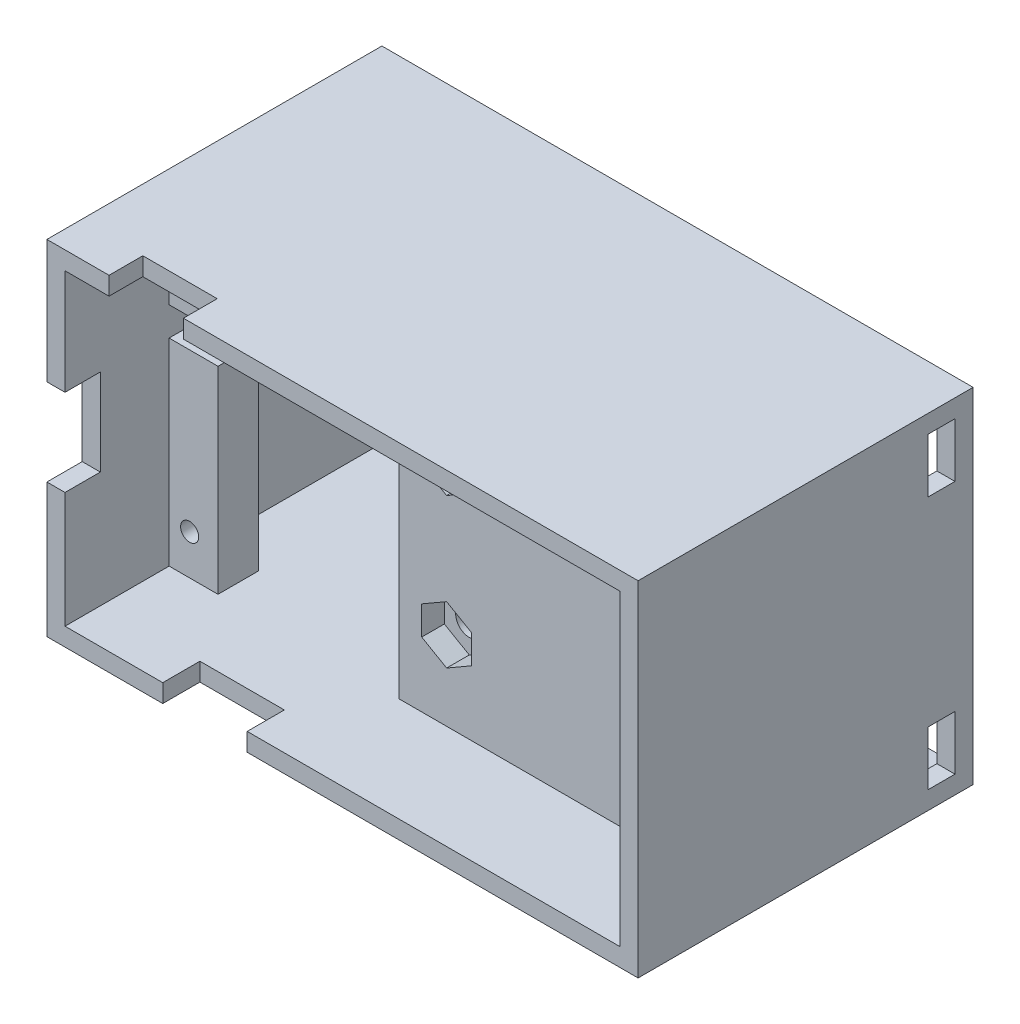
from build123d import *

# Parameters (mm, degrees)
SKETCH_2_W           = 65.2997206
SKETCH_2_H           = 38
SKETCH_2_R           = 1.00000254
SKETCH_2_R_2         = 0.922218434
SKETCH_2_R_3         = 1.5
EXTRUDE_2_DEPTH      = 4.5
SKETCH_3_R           = 1.5
CUT_EXTRUDE_2_DEPTH  = 2.5
SKETCH_5_W           = 65.2997206
SKETCH_5_H           = 38
SKETCH_5_W_2         = 61.2997206
SKETCH_5_H_2         = 34
EXTRUDE_3_DEPTH      = 21
EXTRUDE_3_DEPTH_BACK = 16
SKETCH_7_W           = 8.214112973
SKETCH_7_H           = 3.795011114
CUT_EXTRUDE_4_DEPTH  = 3
SKETCH_8_W           = 4
SKETCH_8_H           = 9.575559499
CUT_EXTRUDE_5_DEPTH  = 3
SKETCH_9_W           = 9.326303795
SKETCH_9_H           = 4.202278939
CUT_EXTRUDE_6_DEPTH  = 3
CUT_EXTRUDE_7_DEPTH  = 10
SKETCH_15_R          = 1.75
CUT_EXTRUDE_8_DEPTH  = 1.5
SKETCH_18_W          = 62.2997206
SKETCH_18_H          = 36
CUT_EXTRUDE_9_DEPTH  = 3
SKETCH_19_W          = 3
SKETCH_19_H          = 6
CUT_EXTRUDE_10_DEPTH = 2
SKETCH_20_W          = 2
SKETCH_20_H          = 8
CUT_EXTRUDE_11_DEPTH = 3
SKETCH_21_W          = 4.5
SKETCH_21_H          = 8
EXTRUDE_4_DEPTH      = 8
SKETCH_22_R          = 1.5
CUT_EXTRUDE_12_DEPTH = 10
CUT_EXTRUDE_13_DEPTH = 2.5
FILLET_1_R           = 1


with BuildPart() as part:
    # 草图2 → 凸台-拉伸2 (new body)
    with BuildSketch(Plane(origin=(0, 0, -6), x_dir=(-1, 0, 0), z_dir=(0, 0, -1))):
        with Locations((29.273558547, -24.066548133)):
            Rectangle(SKETCH_2_W, SKETCH_2_H)
        with Locations((1.016002032, -11.24978156)):
            Circle(SKETCH_2_R, mode=Mode.SUBTRACT)
        with Locations((0.889001778, -36.83007366)):
            Circle(SKETCH_2_R, mode=Mode.SUBTRACT)
        with Locations((57.658115316, -36.64983236)):
            Circle(SKETCH_2_R, mode=Mode.SUBTRACT)
        with Locations((57.658115316, -11.24978156)):
            Circle(SKETCH_2_R_2, mode=Mode.SUBTRACT)
        with Locations((29.273558547, -32.316548133)):
            Circle(SKETCH_2_R_3, mode=Mode.SUBTRACT)
        with BuildLine():
            Line((27.785407033, -15.816548133), (27.785407033, -13.183619987))
            ThreePointArc((27.785407033, -13.183619987), (29.273558547, -11.695468472), (30.761710061, -13.183619987))
            Line((30.761710061, -13.183619987), (30.761710061, -15.816548133))
            ThreePointArc((30.761710061, -15.816548133), (29.273558547, -17.304699647), (27.785407033, -15.816548133))
        make_face(mode=Mode.SUBTRACT)
    extrude(amount=EXTRUDE_2_DEPTH)

    # 草图3 → 切除-拉伸2 (cut)
    with BuildSketch(Plane(origin=(0, 0, -6), x_dir=(-1, 0, 0), z_dir=(0, 0, -1))):
        Polygon((29.273558547, -18.991974614), (32.023558547, -17.404261373), (32.023558547, -14.920341582), (32.023558547, -14.228834893), (32.023558547, -11.744915102), (29.273558547, -10.157201862), (26.523558547, -11.744915102), (26.523558547, -14.228834893), (26.523558547, -14.920341582), (26.523558547, -17.404261373), align=None)
        with BuildLine():
            ThreePointArc((30.761710061, -15.816548133), (29.273558547, -17.304699647), (27.785407033, -15.816548133))
            Line((27.785407033, -15.816548133), (27.785407033, -13.183619987))
            ThreePointArc((27.785407033, -13.183619987), (29.273558547, -11.695468472), (30.761710061, -13.183619987))
            Line((30.761710061, -13.183619987), (30.761710061, -15.816548133))
        make_face(mode=Mode.SUBTRACT)
        Polygon((26.523558547, -30.728834893), (26.523558547, -33.904261373), (29.273558547, -35.491974614), (32.023558547, -33.904261373), (32.023558547, -30.728834893), (29.273558547, -29.141121653), align=None)
        with Locations((29.273558547, -32.316548133)):
            Circle(SKETCH_3_R, mode=Mode.SUBTRACT)
    extrude(amount=CUT_EXTRUDE_2_DEPTH, mode=Mode.SUBTRACT)

    # 草图5 → 凸台-拉伸3 (add, two sides)
    with BuildSketch(Plane(origin=(0, 0, -10.5), x_dir=(-1, 0, 0), z_dir=(0, 0, -1))) as extrude_3_sk:
        with Locations((29.273558547, -24.066548133)):
            Rectangle(SKETCH_5_W, SKETCH_5_H)
        with Locations((29.273558547, -24.066548133)):
            Rectangle(SKETCH_5_W_2, SKETCH_5_H_2, mode=Mode.SUBTRACT)
    extrude(amount=EXTRUDE_3_DEPTH)
    extrude(extrude_3_sk.sketch, amount=-EXTRUDE_3_DEPTH_BACK)

    # 草图7 → 切除-拉伸4 (cut)
    with BuildSketch(Plane(origin=(0, -5.066548133, 0), x_dir=(1, 0, 0), z_dir=(0, 1, 0))):
        with Locations((-50.955145133, -3.662545243)):
            Rectangle(SKETCH_7_W, SKETCH_7_H)
    extrude(amount=-CUT_EXTRUDE_4_DEPTH, mode=Mode.SUBTRACT)

    # 草图8 → 切除-拉伸5 (cut)
    with BuildSketch(Plane.ZY.offset(61.923418847)):
        with Locations((3.6000508, -23.483057223)):
            Rectangle(SKETCH_8_W, SKETCH_8_H)
    extrude(amount=-CUT_EXTRUDE_5_DEPTH, mode=Mode.SUBTRACT)

    # 草图9 → 切除-拉伸6 (cut)
    with BuildSketch(Plane.XZ.offset(43.066548133)):
        with Locations((-44.464129124, 3.49891133)):
            Rectangle(SKETCH_9_W, SKETCH_9_H)
    extrude(amount=-CUT_EXTRUDE_6_DEPTH, mode=Mode.SUBTRACT)

    # 草图13 → 切除-拉伸7 (cut)
    with BuildSketch(Plane.XY.offset(-6)):
        Polygon((-59.923418847, -16.066514367), (-59.923418847, -19.252115931), (-54.525349934, -19.252115931), (-54.525349934, -41.066548133), (-34.525349934, -41.066548133), (-34.525349934, -7.066548133), (-54.525349934, -7.066548133), (-54.525349934, -12.880912803), (-54.525349934, -16.066514367), align=None)
    extrude(amount=-CUT_EXTRUDE_7_DEPTH, mode=Mode.SUBTRACT)

    # 草图15 → 切除-拉伸8 (cut)
    with BuildSketch(Plane(origin=(0, 0, -10.5), x_dir=(-1, 0, 0), z_dir=(0, 0, -1))):
        with Locations((1.016002032, -11.24978156)):
            Circle(SKETCH_15_R)
        with Locations((57.658115316, -11.24978156)):
            Circle(SKETCH_15_R)
        with Locations((0.889001778, -36.83007366)):
            Circle(SKETCH_15_R)
        with Locations((57.658115316, -36.64983236)):
            Circle(SKETCH_15_R)
    extrude(amount=-CUT_EXTRUDE_8_DEPTH, mode=Mode.SUBTRACT)

    # 草图18 → 切除-拉伸9 (cut)
    with BuildSketch(Plane(origin=(0, 0, -31.5), x_dir=(-1, 0, 0), z_dir=(0, 0, -1))):
        with Locations((29.773558547, -24.066548133)):
            Rectangle(SKETCH_18_W, SKETCH_18_H)
    extrude(amount=-CUT_EXTRUDE_9_DEPTH, mode=Mode.SUBTRACT)

    # 草图19 → 切除-拉伸10 (cut)
    with BuildSketch(Plane.ZY.offset(-1.376301753)):
        with Locations((-28, -10.066548133)):
            Rectangle(SKETCH_19_W, SKETCH_19_H)
        with Locations((-28, -38.066548133)):
            Rectangle(SKETCH_19_W, SKETCH_19_H)
    extrude(amount=-CUT_EXTRUDE_10_DEPTH, mode=Mode.SUBTRACT)

    # 草图20 → 切除-拉伸11 (cut)
    with BuildSketch(Plane(origin=(0, 0, -31.5), x_dir=(-1, 0, 0), z_dir=(0, 0, -1))):
        with Locations((60.923418847, -24.066548133)):
            Rectangle(SKETCH_20_W, SKETCH_20_H)
    extrude(amount=-CUT_EXTRUDE_11_DEPTH, mode=Mode.SUBTRACT)

    # 草图21 → 凸台-拉伸4 (add)
    with BuildSketch(Plane.ZY.offset(61.923418847)):
        with Locations((-26.25, -24.066548133)):
            Rectangle(SKETCH_21_W, SKETCH_21_H)
    extrude(amount=EXTRUDE_4_DEPTH)

    # 草图22 → 切除-拉伸12 (cut)
    with BuildSketch(Plane.XY.offset(-24)):
        with Locations((-65.923418847, -24.066548133)):
            Circle(SKETCH_22_R)
    extrude(amount=-CUT_EXTRUDE_12_DEPTH, mode=Mode.SUBTRACT)

    # 草图23 → 切除-拉伸13 (cut)
    with BuildSketch(Plane.XY.offset(-24)):
        Polygon((-64.335705607, -26.816548133), (-62.747992366, -24.066548133), (-64.335705607, -21.316548133), (-67.511132087, -21.316548133), (-69.098845327, -24.066548133), (-67.511132087, -26.816548133), align=None)
    extrude(amount=-CUT_EXTRUDE_13_DEPTH, mode=Mode.SUBTRACT)

    # 圆角1
    fillet_1_edges = [part.edges().sort_by_distance(p)[0] for p in [
        (-69.923418847, -28.066548133, -26.25),
        (-69.923418847, -20.066548133, -26.25),
    ]]
    fillet(fillet_1_edges, radius=FILLET_1_R)


solid = part.part
